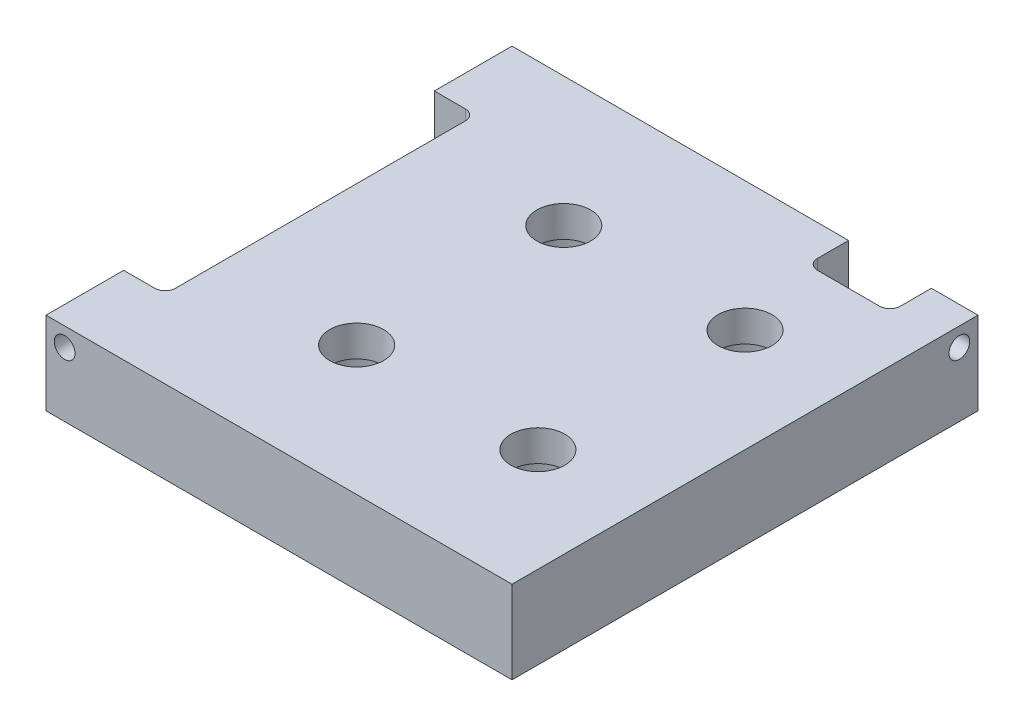
from build123d import *

# Parameters (mm, degrees)
SKETCH_1_W           = 45
SKETCH_1_H           = 45
EXTRUDE_1_DEPTH      = 8
SKETCH_2_R           = 2.6
CUT_EXTRUDE_1_DEPTH  = 9
SKETCH_3_R           = 4.4
CUT_EXTRUDE_2_DEPTH  = 5
SKETCH_5_W           = 4
SKETCH_5_H           = 30
CUT_EXTRUDE_4_DEPTH  = 4
SKETCH_6_R           = 1
CUT_EXTRUDE_5_DEPTH  = 9
FILLET_1_R           = 1
SKETCH_7_W           = 8
SKETCH_7_H           = 4
CUT_EXTRUDE_6_DEPTH  = 4
FILLET_2_R           = 1
SKETCH_8_R           = 1
CUT_EXTRUDE_7_DEPTH  = 9
SKETCH_11_R          = 1.5
CUT_EXTRUDE_10_DEPTH = 3


with BuildPart() as part:
    # 草图1 → 凸台-拉伸1 (new body)
    with BuildSketch(Plane(origin=(0, 0, 0), x_dir=(1, 0, 0), z_dir=(0, 1, 0))):
        with Locations((22.5, 22.5)):
            Rectangle(SKETCH_1_W, SKETCH_1_H)
    extrude(amount=EXTRUDE_1_DEPTH)

    # 草图2 → 切除-拉伸1 (cut, through all)
    with BuildSketch(Plane(origin=(0, 8, 0), x_dir=(1, 0, 0), z_dir=(0, 1, 0))):
        with Locations((17.5, 12.5)):
            Circle(SKETCH_2_R)
        with Locations((17.5, 32.5)):
            Circle(SKETCH_2_R)
        with Locations((35, 12.5)):
            Circle(SKETCH_2_R)
        with Locations((35, 32.5)):
            Circle(SKETCH_2_R)
    extrude(amount=-CUT_EXTRUDE_1_DEPTH, mode=Mode.SUBTRACT)

    # 草图3 → 切除-拉伸2 (cut)
    with BuildSketch(Plane(origin=(0, 0, 0), x_dir=(-1, 0, 0), z_dir=(0, -1, 0))):
        with Locations((-17.5, 32.5)):
            Circle(SKETCH_3_R)
        with Locations((-17.5, 12.5)):
            Circle(SKETCH_3_R)
        with Locations((-35, 12.5)):
            Circle(SKETCH_3_R)
        with Locations((-35, 32.5)):
            Circle(SKETCH_3_R)
    extrude(amount=-CUT_EXTRUDE_2_DEPTH, mode=Mode.SUBTRACT)

    # 草图5 → 切除-拉伸4 (cut)
    with BuildSketch(Plane(origin=(0, 8, 0), x_dir=(1, 0, 0), z_dir=(0, 1, 0))):
        with Locations((2, 22.5)):
            Rectangle(SKETCH_5_W, SKETCH_5_H)
    extrude(amount=-CUT_EXTRUDE_4_DEPTH, mode=Mode.SUBTRACT)

    # 草图6 → 切除-拉伸5 (cut)
    with BuildSketch(Plane.XY):
        with Locations((1.8, 6.2)):
            Circle(SKETCH_6_R)
    extrude(amount=-CUT_EXTRUDE_5_DEPTH, mode=Mode.SUBTRACT)

    # 圆角1
    fillet_1_edges = [part.edges().sort_by_distance(p)[0] for p in [
        (4, 6, -37.5),
        (4, 6, -7.5),
    ]]
    fillet(fillet_1_edges, radius=FILLET_1_R)

    # 草图7 → 切除-拉伸6 (cut)
    with BuildSketch(Plane(origin=(0, 8, 0), x_dir=(1, 0, 0), z_dir=(0, 1, 0))):
        with Locations((36.5, 43)):
            Rectangle(SKETCH_7_W, SKETCH_7_H)
    extrude(amount=-CUT_EXTRUDE_6_DEPTH, mode=Mode.SUBTRACT)

    # 圆角2
    fillet_2_edges = [part.edges().sort_by_distance(p)[0] for p in [
        (40.5, 6, -41),
        (32.5, 6, -41),
    ]]
    fillet(fillet_2_edges, radius=FILLET_2_R)

    # 草图8 → 切除-拉伸7 (cut)
    with BuildSketch(Plane(origin=(45, 0, 0), x_dir=(0, 0, -1), z_dir=(1, 0, 0))):
        with Locations((43.2, 6.2)):
            Circle(SKETCH_8_R)
    extrude(amount=-CUT_EXTRUDE_7_DEPTH, mode=Mode.SUBTRACT)

    # 草图11 → 切除-拉伸10 (cut)
    with BuildSketch(Plane(origin=(0, 0, 0), x_dir=(-1, 0, 0), z_dir=(0, -1, 0))):
        with Locations((-4, 4)):
            Circle(SKETCH_11_R)
        with Locations((-41, 4)):
            Circle(SKETCH_11_R)
        with Locations((-4, 41)):
            Circle(SKETCH_11_R)
        with Locations((-41, 41)):
            Circle(SKETCH_11_R)
    extrude(amount=-CUT_EXTRUDE_10_DEPTH, mode=Mode.SUBTRACT)


solid = part.part
